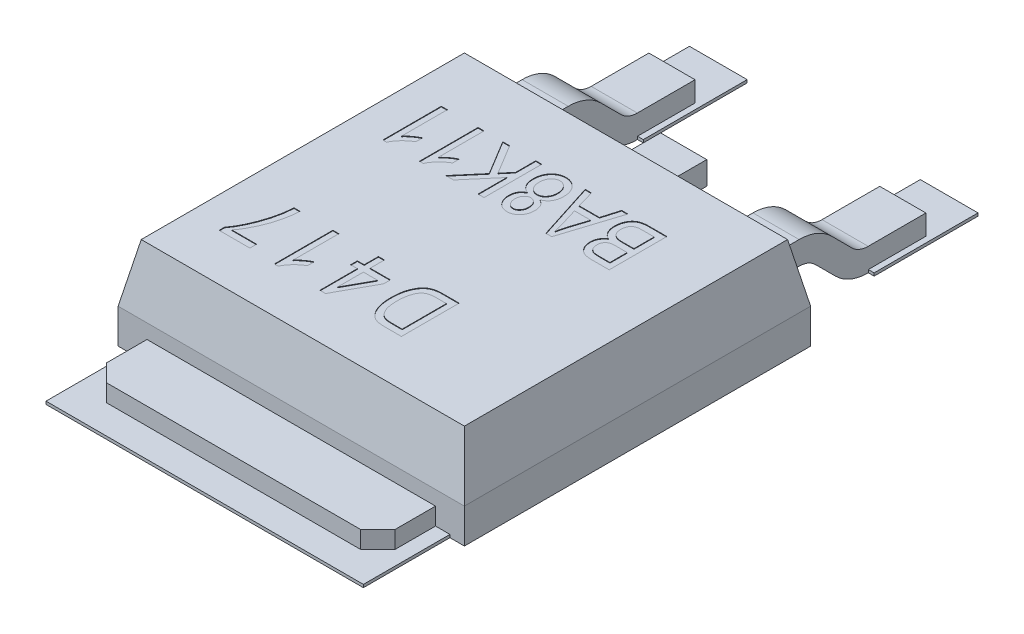
from build123d import *
from OCP.BRepFilletAPI import BRepFilletAPI_MakeChamfer

# Parameters (mm, degrees)
SKETCH1_W           = 6
SKETCH1_H           = 6
BOSS_EXTRUDE1_DEPTH = 1.6
CHAMFER1_SIZE       = 1
CHAMFER1_SIZE2      = 0.2
BOSS_EXTRU_1_DEPTH  = 0.35
SKETCH4_W           = 5.5
SKETCH4_H           = 2
SKETCH4_W_2         = 1
SKETCH4_H_2         = 1.8
BOSS_EXTRUDE2_DEPTH = 0.05
CUT_EXTRUDE1_DEPTH  = 0.01
CUT_EXTRUDE2_DEPTH  = 0.01
EXTRU_MINCE1_DEPTH  = 0.4
ESQUISSE3_W         = 1
ESQUISSE3_H         = 0.4
EXTRU_MINCE2_DEPTH  = 0.4


with BuildPart() as part:
    # Sketch1 → Boss-Extrude1 (new body)
    with BuildSketch(Plane(origin=(0, 0, 0), x_dir=(1, 0, 0), z_dir=(0, 1, 0))):
        Rectangle(SKETCH1_W, SKETCH1_H)
    extrude(amount=BOSS_EXTRUDE1_DEPTH)

    # Chamfer1: one chamfer whose edges measure the first distance from different faces: ONE call of the kernel's chamfer builder (chamfer() names one face for all edges)
    chamfer1_edges_1 = [part.edges().sort_by_distance(p)[0] for p in [
        (3, 1.6, 0),
    ]]
    chamfer1_side_1 = [part.faces().sort_by_distance(p)[0] for p in [
        (3, 0.8, 0),
    ]]
    chamfer1_edges_2 = [part.edges().sort_by_distance(p)[0] for p in [
        (0, 1.6, -3),
    ]]
    chamfer1_side_2 = [part.faces().sort_by_distance(p)[0] for p in [
        (0, 0.8, -3),
    ]]
    chamfer1_edges_3 = [part.edges().sort_by_distance(p)[0] for p in [
        (-3, 1.6, 0),
    ]]
    chamfer1_side_3 = [part.faces().sort_by_distance(p)[0] for p in [
        (-3, 0.8, 0),
    ]]
    chamfer1_edges_4 = [part.edges().sort_by_distance(p)[0] for p in [
        (0, 1.6, 3),
    ]]
    chamfer1_side_4 = [part.faces().sort_by_distance(p)[0] for p in [
        (0, 0.8, 3),
    ]]
    chamfer1 = BRepFilletAPI_MakeChamfer(part.part.solid().wrapped)
    for e in chamfer1_edges_1:
        chamfer1.Add(CHAMFER1_SIZE, CHAMFER1_SIZE2, e.wrapped, chamfer1_side_1[0].wrapped)  # the first distance lies on this face
    for e in chamfer1_edges_2:
        chamfer1.Add(CHAMFER1_SIZE, CHAMFER1_SIZE2, e.wrapped, chamfer1_side_2[0].wrapped)  # the first distance lies on this face
    for e in chamfer1_edges_3:
        chamfer1.Add(CHAMFER1_SIZE, CHAMFER1_SIZE2, e.wrapped, chamfer1_side_3[0].wrapped)  # the first distance lies on this face
    for e in chamfer1_edges_4:
        chamfer1.Add(CHAMFER1_SIZE, CHAMFER1_SIZE2, e.wrapped, chamfer1_side_4[0].wrapped)  # the first distance lies on this face
    add(Compound.cast(chamfer1.Shape()), mode=Mode.REPLACE)

    # Esquisse1 → Boss.-Extru.1 (add)
    with BuildSketch(Plane.XZ):
        Polygon((-2.5, 3), (-2.5, 3.7), (-2.2, 4), (2.2, 4), (2.5, 3.7), (2.5, 3), align=None)
    extrude(amount=-BOSS_EXTRU_1_DEPTH)

    # Sketch4 → Boss-Extrude2 (add)
    with BuildSketch(Plane(origin=(0, 0, 0), x_dir=(1, 0, 0), z_dir=(0, 1, 0))):
        with Locations((0, -3.5)):
            Rectangle(SKETCH4_W, SKETCH4_H)
        with Locations((-2, 5.5)):
            Rectangle(SKETCH4_W_2, SKETCH4_H_2)
        with Locations((2, 5.5)):
            Rectangle(SKETCH4_W_2, SKETCH4_H_2)
    extrude(amount=BOSS_EXTRUDE2_DEPTH)


with BuildPart() as boss_extrude2_piece_1:
    # of the separate pieces the step leaves, piece 1, a body of its own (boss_extrude2_pieces)
    add(part.part.solids().sort_by_distance((-3, 0.6, -3))[0])

    # Sketch5 → Cut-Extrude1 (cut)
    with BuildSketch(Plane(origin=(0, 1.6, 0), x_dir=(1, 0, 0), z_dir=(0, 1, 0))):
        with BuildLine():
            Line((0.909090909, -1), (0.909090909, -2))
            Line((0.909090909, -2), (0.627232143, -2))
            add(Edge.make_bspline(
                [(0.627232143, -2), (0.618775412, -2.00000451), (0.60239621, -2.000013245), (0.578587199, -1.998844327), (0.556316091, -1.997536776), (0.535597034, -1.995541178), (0.516529087, -1.992843094), (0.498939821, -1.989939618), (0.482975595, -1.986074805), (0.472930515, -1.983000063), (0.468141234, -1.981534091)],
                knots=[0, 0, 0, 0, 1.262174937, 2.444611131, 3.557536157, 4.59237566, 5.550534478, 6.431992477, 7.252407118, 8, 8, 8, 8], degree=3))
            add(Edge.make_bspline(
                [(0.468141234, -1.981534091), (0.456481577, -1.977077241), (0.433154022, -1.96816039), (0.400785725, -1.948392912), (0.370967262, -1.923721279), (0.343505704, -1.894318821), (0.318800848, -1.860334626), (0.297135486, -1.822023974), (0.278003099, -1.779895789), (0.26197546, -1.733511256), (0.249196519, -1.682818235), (0.240254127, -1.627627934), (0.23471847, -1.568024588), (0.234090817, -1.526798491), (0.233766234, -1.505478896)],
                knots=[0, 0, 0, 0, 0.793570228, 1.587701398, 2.401757725, 3.251990999, 4.14284781, 5.070886882, 6.05016333, 7.085482446, 8.191842001, 9.375152492, 10.642590783, 12, 12, 12, 12], degree=3))
            add(Edge.make_bspline(
                [(0.233766234, -1.505478896), (0.233936524, -1.491609851), (0.234271511, -1.464327235), (0.236476558, -1.424242192), (0.240312254, -1.385711603), (0.245787602, -1.348883148), (0.252663112, -1.313580679), (0.261094381, -1.279946144), (0.271346301, -1.247947411), (0.282845805, -1.217593758), (0.295542964, -1.189045638), (0.309363547, -1.1626511), (0.323967898, -1.138314333), (0.339601771, -1.116289027), (0.355796369, -1.096150943), (0.373181339, -1.078498187), (0.391220094, -1.062685269), (0.410533963, -1.049188647), (0.431048809, -1.03758525), (0.452795028, -1.027390955), (0.476077229, -1.018828152), (0.500887314, -1.012045721), (0.527097788, -1.006515321), (0.554830261, -1.002702364), (0.584041134, -1.000496637), (0.604027564, -1.000168005), (0.61424513, -1)],
                knots=[0, 0, 0, 0, 1.386035777, 2.726552658, 4.010606465, 5.254366226, 6.446193604, 7.603690686, 8.717510246, 9.802231389, 10.846187194, 11.837930809, 12.77813523, 13.6802668, 14.53543628, 15.357642445, 16.153183888, 16.929597682, 17.707687034, 18.506066684, 19.327327497, 20.183458262, 21.074376462, 22.002646263, 22.978902547, 24, 24, 24, 24], degree=3))
            Line((0.61424513, -1), (0.909090909, -1))
        make_face()
        with BuildLine():
            Line((0.805194805, -1.116883117), (0.626826299, -1.116883117))
            add(Edge.make_bspline(
                [(0.626826299, -1.116883117), (0.618097699, -1.117005877), (0.601166151, -1.117244005), (0.576588709, -1.118906443), (0.553598984, -1.12141978), (0.53226459, -1.125313856), (0.512582747, -1.130105742), (0.494498004, -1.135992591), (0.478070061, -1.143079418), (0.463030763, -1.15126581), (0.44932786, -1.16069055), (0.436604076, -1.171408607), (0.424660749, -1.18336333), (0.413499295, -1.196621802), (0.403028313, -1.211046266), (0.393783985, -1.227072232), (0.384996644, -1.244233052), (0.3799878, -1.256386977), (0.377435065, -1.262581169)],
                knots=[0, 0, 0, 0, 1.342522454, 2.604195873, 3.787640691, 4.897837639, 5.937490788, 6.901507558, 7.81956877, 8.685632238, 9.531204737, 10.37312076, 11.241244131, 12.127141563, 13.036673505, 13.978826353, 14.969918024, 16, 16, 16, 16], degree=3))
            add(Edge.make_bspline(
                [(0.377435065, -1.262581169), (0.374235057, -1.271275904), (0.367767595, -1.28884863), (0.359550223, -1.316254887), (0.353107863, -1.344993201), (0.347201712, -1.374924433), (0.343189551, -1.406125809), (0.339760984, -1.438585087), (0.338026764, -1.472315755), (0.33778495, -1.495263627), (0.337662338, -1.506899351)],
                knots=[0, 0, 0, 0, 0.893151802, 1.805128209, 2.755850574, 3.731738016, 4.745334486, 5.787480394, 6.878141491, 8, 8, 8, 8], degree=3))
            add(Edge.make_bspline(
                [(0.337662338, -1.506899351), (0.337751243, -1.51928112), (0.337924325, -1.543386024), (0.340069251, -1.578512545), (0.343150431, -1.611578414), (0.347889282, -1.64258153), (0.353717899, -1.671581071), (0.3606963, -1.698616756), (0.369273581, -1.723571691), (0.379178025, -1.746475475), (0.390248858, -1.767369446), (0.401717861, -1.786658084), (0.414363885, -1.803853952), (0.42754419, -1.819364746), (0.441467336, -1.833160595), (0.456190791, -1.845094558), (0.471786112, -1.855222075), (0.48275985, -1.860566298), (0.488230519, -1.863230519)],
                knots=[0, 0, 0, 0, 1.456515219, 2.835552549, 4.138945756, 5.362336007, 6.523499621, 7.617953034, 8.644754834, 9.624918001, 10.550413316, 11.425253886, 12.262512803, 13.058355621, 13.818045382, 14.564998839, 15.284617782, 16, 16, 16, 16], degree=3))
            add(Edge.make_bspline(
                [(0.488230519, -1.863230519), (0.492196312, -1.864856582), (0.500541033, -1.868278102), (0.514225775, -1.872201089), (0.529448542, -1.875715827), (0.546367242, -1.878175199), (0.564826162, -1.880463596), (0.584997618, -1.882110126), (0.606800225, -1.882783141), (0.62188835, -1.883003351), (0.629667208, -1.883116883)],
                knots=[0, 0, 0, 0, 0.715292366, 1.505100173, 2.373764653, 3.322734101, 4.358121183, 5.480036167, 6.700803291, 8, 8, 8, 8], degree=3))
            Line((0.629667208, -1.883116883), (0.805194805, -1.883116883))
            Line((0.805194805, -1.883116883), (0.805194805, -1.116883117))
        make_face(mode=Mode.SUBTRACT)
        Polygon((-0.386363636, -1), (-0.386363636, -1.246753247), (-0.035714286, -1.246753247), (-0.035714286, -1.363636364), (-0.392248377, -2.012987013), (-0.49025974, -2.012987013), (-0.49025974, -1.363636364), (-0.607142857, -1.363636364), (-0.607142857, -1.246753247), (-0.49025974, -1.246753247), (-0.49025974, -1), align=None)
        Polygon((-0.386363636, -1.363636364), (-0.386363636, -1.815543831), (-0.138189935, -1.363636364), align=None, mode=Mode.SUBTRACT)
        with BuildLine():
            Line((-1.279220779, -1), (-1.175324675, -1))
            Line((-1.175324675, -1), (-1.175324675, -1.792207792))
            add(Edge.make_bspline(
                [(-1.175324675, -1.792207792), (-1.168941155, -1.784866534), (-1.155711315, -1.769651785), (-1.132836194, -1.747977094), (-1.107121801, -1.725961756), (-1.079062769, -1.70412581), (-1.050104506, -1.683443988), (-1.021591711, -1.665041869), (-0.994416181, -1.649140319), (-0.976251606, -1.640507471), (-0.967532468, -1.636363636)],
                knots=[0, 0, 0, 0, 0.892597597, 1.849907605, 2.889096657, 3.999508354, 5.112538398, 6.154543284, 7.114166246, 8, 8, 8, 8], degree=3))
            Line((-0.967532468, -1.636363636), (-0.967532468, -1.753246753))
            add(Edge.make_bspline(
                [(-0.967532468, -1.753246753), (-0.981542686, -1.761684938), (-1.009443158, -1.778489054), (-1.048633979, -1.807549853), (-1.085439436, -1.839249281), (-1.119295093, -1.873145958), (-1.149602414, -1.908063441), (-1.175168336, -1.943201804), (-1.196425732, -1.977703086), (-1.206826798, -2.00149514), (-1.211850649, -2.012987013)],
                knots=[0, 0, 0, 0, 1.082266703, 2.155266233, 3.225308806, 4.295585612, 5.324342242, 6.282751181, 7.17054637, 8, 8, 8, 8], degree=3))
            Line((-1.211850649, -2.012987013), (-1.279220779, -2.012987013))
            Line((-1.279220779, -2.012987013), (-1.279220779, -1))
        make_face()
        with BuildLine():
            Line((-1.730519481, -1.87012987), (-1.730519481, -1.987012987))
            Line((-1.730519481, -1.987012987), (-2.262987013, -1.987012987))
            Line((-2.262987013, -1.987012987), (-2.262987013, -1.891436688))
            add(Edge.make_bspline(
                [(-2.262987013, -1.891436688), (-2.253107587, -1.878210031), (-2.232998474, -1.851287786), (-2.204877796, -1.808222134), (-2.177523491, -1.762359182), (-2.150938602, -1.713647147), (-2.125334602, -1.662005922), (-2.100887544, -1.607370332), (-2.077158554, -1.54991053), (-2.054393858, -1.490126812), (-2.033180943, -1.428934513), (-2.014319685, -1.367266072), (-1.997878532, -1.305656703), (-1.983655189, -1.244287077), (-1.971819574, -1.183038154), (-1.962512462, -1.121977409), (-1.955512302, -1.060986446), (-1.952701618, -1.020305417), (-1.951298701, -1)],
                knots=[0, 0, 0, 0, 0.828261285, 1.685887316, 2.579428271, 3.507501538, 4.469891598, 5.471065063, 6.510494938, 7.589089173, 8.680758398, 9.759817177, 10.82439165, 11.879940066, 12.920405774, 13.953938893, 14.978734705, 16, 16, 16, 16], degree=3))
            Line((-1.951298701, -1), (-1.847402597, -1))
            add(Edge.make_bspline(
                [(-1.847402597, -1), (-1.847750245, -1.010689632), (-1.848459293, -1.032491751), (-1.850659887, -1.065872605), (-1.854401087, -1.100508476), (-1.859272188, -1.1365078), (-1.865445265, -1.173762929), (-1.872455889, -1.212439498), (-1.881062772, -1.252330181), (-1.894016685, -1.307156239), (-1.912517131, -1.375703545), (-1.93909059, -1.456512779), (-1.969148541, -1.535436954), (-2.003256405, -1.611554138), (-2.039186803, -1.684140455), (-2.07765803, -1.751351867), (-2.116488053, -1.813642595), (-2.145154103, -1.85165101), (-2.159090909, -1.87012987)],
                knots=[0, 0, 0, 0, 0.547564817, 1.116789984, 1.712252562, 2.330831182, 2.976456312, 3.645516887, 4.343080939, 5.06547646, 6.529779861, 7.976466419, 9.419056042, 10.851576025, 12.245448489, 13.563727135, 14.815537433, 16, 16, 16, 16], degree=3))
            Line((-2.159090909, -1.87012987), (-1.730519481, -1.87012987))
        make_face()
    extrude(amount=-CUT_EXTRUDE1_DEPTH, mode=Mode.SUBTRACT)

    # Sketch6 → Cut-Extrude2 (cut)
    with BuildSketch(Plane(origin=(0, 1.6, 0), x_dir=(1, 0, 0), z_dir=(0, 1, 0))):
        with BuildLine():
            Line((1.709090909, 1.8), (1.709090909, 0.8))
            Line((1.709090909, 0.8), (1.399025974, 0.8))
            add(Edge.make_bspline(
                [(1.399025974, 0.8), (1.391379972, 0.800054737), (1.376479609, 0.800161407), (1.35474923, 0.801658249), (1.334234107, 0.803862586), (1.314898025, 0.806818804), (1.296886513, 0.810896293), (1.280041716, 0.815744905), (1.264459217, 0.821633249), (1.245258892, 0.830494742), (1.223120185, 0.844304649), (1.199134695, 0.864843401), (1.177779684, 0.889492317), (1.159040297, 0.917539877), (1.143625845, 0.948366452), (1.132659113, 0.981294216), (1.125938203, 1.015839329), (1.125101346, 1.039417471), (1.124675325, 1.051420455)],
                knots=[0, 0, 0, 0, 0.870762362, 1.696922705, 2.479694412, 3.220704395, 3.923519284, 4.58180529, 5.215744372, 5.818975064, 6.988484834, 8.174326093, 9.402850172, 10.691394685, 12.007628492, 13.315991423, 14.633645104, 16, 16, 16, 16], degree=3))
            add(Edge.make_bspline(
                [(1.124675325, 1.051420455), (1.125012224, 1.062469532), (1.125673818, 1.084167395), (1.131294903, 1.115801747), (1.140432431, 1.145758504), (1.153339228, 1.173770644), (1.169199712, 1.19991493), (1.18879568, 1.223013033), (1.210790177, 1.244063188), (1.227706367, 1.255327982), (1.236282468, 1.261038961)],
                knots=[0, 0, 0, 0, 1.067163608, 2.095665496, 3.094381775, 4.086055985, 5.069334826, 6.039400011, 7.006023047, 8, 8, 8, 8], degree=3))
            add(Edge.make_bspline(
                [(1.236282468, 1.261038961), (1.22600209, 1.265827966), (1.205531205, 1.275364113), (1.178368523, 1.29598836), (1.15440453, 1.320887189), (1.134393073, 1.35051673), (1.118310935, 1.384223727), (1.106796572, 1.421742795), (1.099812443, 1.462889136), (1.099080571, 1.49152962), (1.098701299, 1.506371753)],
                knots=[0, 0, 0, 0, 0.907806387, 1.807676924, 2.717428127, 3.670336734, 4.663211712, 5.703492116, 6.809898713, 8, 8, 8, 8], degree=3))
            add(Edge.make_bspline(
                [(1.098701299, 1.506371753), (1.099078652, 1.521283338), (1.099811987, 1.550262045), (1.106983705, 1.592270609), (1.118188705, 1.631554649), (1.134224832, 1.66761609), (1.154018015, 1.699906758), (1.177096466, 1.727895878), (1.203311481, 1.751153558), (1.227873534, 1.766535285), (1.249305953, 1.77614511), (1.266729866, 1.782748339), (1.285740342, 1.787857683), (1.306033096, 1.792382826), (1.327857783, 1.795816529), (1.351100626, 1.798103731), (1.375730043, 1.799903222), (1.39259649, 1.799967164), (1.401258117, 1.8)],
                knots=[0, 0, 0, 0, 1.483101461, 2.882213003, 4.228804869, 5.540004403, 6.797554673, 7.988070595, 9.137672878, 10.271731903, 10.856259808, 11.474079914, 12.124255131, 12.813652303, 13.543114926, 14.321609254, 15.138076009, 16, 16, 16, 16], degree=3))
            Line((1.401258117, 1.8), (1.709090909, 1.8))
        make_face()
        with BuildLine():
            Line((1.605194805, 1.215584416), (1.421753247, 1.215584416))
            add(Edge.make_bspline(
                [(1.421753247, 1.215584416), (1.410653992, 1.215504138), (1.390129319, 1.215355689), (1.361987025, 1.213421056), (1.338789187, 1.211138), (1.325406025, 1.207609396), (1.319480519, 1.206047078)],
                knots=[0, 0, 0, 0, 1.292436319, 2.38996507, 3.287143691, 4, 4, 4, 4], degree=3))
            add(Edge.make_bspline(
                [(1.319480519, 1.206047078), (1.312542258, 1.203575452), (1.298988065, 1.198747023), (1.28083443, 1.187697451), (1.26482608, 1.17461566), (1.251549462, 1.15881063), (1.240829716, 1.140289002), (1.233795941, 1.118658579), (1.229198572, 1.094228534), (1.228787545, 1.076944839), (1.228571429, 1.067857143)],
                knots=[0, 0, 0, 0, 0.985455176, 1.925129435, 2.833409245, 3.74751417, 4.678036112, 5.68496882, 6.782766118, 8, 8, 8, 8], degree=3))
            add(Edge.make_bspline(
                [(1.228571429, 1.067857143), (1.228830522, 1.059315913), (1.229327246, 1.042940959), (1.233478133, 1.019477123), (1.240087212, 0.998185735), (1.2494136, 0.979214978), (1.261076363, 0.962840987), (1.274599342, 0.949004357), (1.2899696, 0.93796315), (1.304319142, 0.930893334), (1.3173713, 0.927006428), (1.328912934, 0.924086669), (1.342370093, 0.921981149), (1.357544365, 0.920246836), (1.37444135, 0.918498491), (1.39313363, 0.917619635), (1.413564079, 0.916981608), (1.427772613, 0.916916766), (1.435146104, 0.916883117)],
                knots=[0, 0, 0, 0, 1.374823033, 2.635763691, 3.824462367, 4.954815379, 6.024974192, 7.049578075, 8.056420344, 9.060192966, 9.608067978, 10.247510764, 10.976465608, 11.799414685, 12.707848295, 13.711620916, 14.812450139, 16, 16, 16, 16], degree=3))
            Line((1.435146104, 0.916883117), (1.605194805, 0.916883117))
            Line((1.605194805, 0.916883117), (1.605194805, 1.215584416))
        make_face(mode=Mode.SUBTRACT)
        with BuildLine():
            Line((1.605194805, 1.683116883), (1.399025974, 1.683116883))
            add(Edge.make_bspline(
                [(1.399025974, 1.683116883), (1.388401593, 1.682961147), (1.368614295, 1.682671096), (1.341133252, 1.680603566), (1.31801264, 1.676848839), (1.304495734, 1.672503054), (1.298376623, 1.670535714)],
                knots=[0, 0, 0, 0, 1.250964288, 2.329849019, 3.243921745, 4, 4, 4, 4], degree=3))
            add(Edge.make_bspline(
                [(1.298376623, 1.670535714), (1.290859518, 1.667282728), (1.276193291, 1.660935997), (1.256844935, 1.647017306), (1.239879566, 1.630785821), (1.226253555, 1.611185955), (1.215635897, 1.588885306), (1.207946016, 1.564023054), (1.203532087, 1.536424303), (1.202917918, 1.517210521), (1.202597403, 1.507183442)],
                knots=[0, 0, 0, 0, 0.967993686, 1.888601442, 2.806833432, 3.738608885, 4.699374536, 5.72357697, 6.812005123, 8, 8, 8, 8], degree=3))
            add(Edge.make_bspline(
                [(1.202597403, 1.507183442), (1.202829078, 1.497896151), (1.203276768, 1.479949339), (1.207868279, 1.454178508), (1.215104403, 1.430588423), (1.225295109, 1.409313134), (1.238065552, 1.390582178), (1.253137342, 1.374614588), (1.26987555, 1.36091141), (1.285804804, 1.352046381), (1.299981138, 1.346382429), (1.312025001, 1.342524545), (1.325641811, 1.339588785), (1.340523686, 1.336941513), (1.356848319, 1.334921668), (1.374525439, 1.333613795), (1.393600033, 1.332453516), (1.406802604, 1.332462752), (1.413636364, 1.332467532)],
                knots=[0, 0, 0, 0, 1.410573788, 2.725800822, 3.964903627, 5.151480749, 6.298041429, 7.396564004, 8.478942006, 9.57457322, 10.151232655, 10.798392405, 11.494360327, 12.266936039, 13.095957466, 13.993447348, 14.961391824, 16, 16, 16, 16], degree=3))
            Line((1.413636364, 1.332467532), (1.605194805, 1.332467532))
            Line((1.605194805, 1.332467532), (1.605194805, 1.683116883))
        make_face(mode=Mode.SUBTRACT)
        Polygon((1.033766234, 1.8), (0.714366883, 0.8), (0.613108766, 0.8), (0.293506494, 1.8), (0.401461039, 1.8), (0.488920455, 1.501298701), (0.838352273, 1.501298701), (0.925608766, 1.8), align=None)
        with BuildLine():
            Line((0.804261364, 1.384415584), (0.523214286, 1.384415584))
            Line((0.523214286, 1.384415584), (0.606818182, 1.109659091))
            add(Edge.make_bspline(
                [(0.606818182, 1.109659091), (0.609943302, 1.099381806), (0.616044644, 1.079316904), (0.624726603, 1.049947394), (0.632908616, 1.022030462), (0.640419515, 0.99560057), (0.647062127, 0.970607104), (0.653235429, 0.947157072), (0.658669278, 0.925160817), (0.662024566, 0.910933488), (0.663636364, 0.904099026)],
                knots=[0, 0, 0, 0, 1.208585302, 2.359586633, 3.44573617, 4.481694954, 5.45087266, 6.355352717, 7.20995158, 8, 8, 8, 8], degree=3))
            add(Edge.make_bspline(
                [(0.663636364, 0.904099026), (0.666559949, 0.920019234), (0.672403236, 0.951838502), (0.683356248, 0.999239199), (0.695541806, 1.04655436), (0.705241061, 1.077769848), (0.710105519, 1.093425325)],
                knots=[0, 0, 0, 0, 0.995500629, 1.989678841, 2.991765375, 4, 4, 4, 4], degree=3))
            Line((0.710105519, 1.093425325), (0.804261364, 1.384415584))
        make_face(mode=Mode.SUBTRACT)
        with BuildLine():
            add(Edge.make_bspline(
                [(0.055073052, 1.251298701), (0.06462921, 1.246491383), (0.083273438, 1.237112222), (0.108139677, 1.218830253), (0.12914444, 1.19737835), (0.146566292, 1.172965679), (0.160360127, 1.145492643), (0.169686672, 1.114812189), (0.175815864, 1.081223702), (0.176347218, 1.057740526), (0.176623377, 1.045535714)],
                knots=[0, 0, 0, 0, 1.008509637, 1.967619574, 2.89776806, 3.831547644, 4.788167516, 5.785783694, 6.849214744, 8, 8, 8, 8], degree=3))
            add(Edge.make_bspline(
                [(0.176623377, 1.045535714), (0.176437496, 1.036192949), (0.176074127, 1.01792923), (0.172968249, 0.99118185), (0.167878134, 0.96582057), (0.161102457, 0.941683442), (0.151850327, 0.919021466), (0.140609062, 0.89768413), (0.127678992, 0.87738583), (0.112439714, 0.85891933), (0.095911173, 0.842089289), (0.078177815, 0.827378272), (0.059412853, 0.814910076), (0.039612401, 0.804691252), (0.018781155, 0.796754339), (-0.003104633, 0.790979993), (-0.02607062, 0.787808644), (-0.041711805, 0.78728051), (-0.04963474, 0.787012987)],
                knots=[0, 0, 0, 0, 1.165741532, 2.278851694, 3.354982323, 4.391648623, 5.402771003, 6.403407807, 7.398581389, 8.400606014, 9.38555839, 10.33889109, 11.270751962, 12.191998689, 13.113864065, 14.047558559, 15.011004111, 16, 16, 16, 16], degree=3))
            add(Edge.make_bspline(
                [(-0.04963474, 0.787012987), (-0.057628477, 0.787257493), (-0.073420297, 0.787740521), (-0.096550565, 0.79124631), (-0.118652568, 0.796951233), (-0.13974026, 0.804861825), (-0.159695435, 0.815329769), (-0.178664421, 0.827989647), (-0.196651133, 0.84291662), (-0.213354584, 0.860076787), (-0.228476677, 0.879063823), (-0.241802257, 0.899480577), (-0.252942164, 0.921272034), (-0.262145499, 0.94436096), (-0.269241336, 0.968830901), (-0.274246983, 0.994639674), (-0.27736951, 1.021717189), (-0.277735543, 1.040183505), (-0.277922078, 1.049594156)],
                knots=[0, 0, 0, 0, 0.984942696, 1.945778183, 2.875853341, 3.793971666, 4.714923987, 5.646678758, 6.59981698, 7.590177482, 8.592638326, 9.586885563, 10.589796896, 11.603734109, 12.645759419, 13.72477449, 14.840518438, 16, 16, 16, 16], degree=3))
            add(Edge.make_bspline(
                [(-0.277922078, 1.049594156), (-0.277623933, 1.061322759), (-0.277049626, 1.083915245), (-0.271179536, 1.116373217), (-0.26194147, 1.146057318), (-0.248872785, 1.173038658), (-0.231761321, 1.197212749), (-0.21060629, 1.218269845), (-0.185967661, 1.23704401), (-0.16723645, 1.246452851), (-0.157589286, 1.251298701)],
                knots=[0, 0, 0, 0, 1.126050265, 2.169079615, 3.157896424, 4.105607084, 5.038058818, 5.989507118, 6.964532763, 8, 8, 8, 8], degree=3))
            add(Edge.make_bspline(
                [(-0.157589286, 1.251298701), (-0.163863221, 1.253825326), (-0.176231325, 1.258806179), (-0.193694264, 1.268119642), (-0.210261126, 1.278221263), (-0.225636349, 1.289600489), (-0.239975187, 1.301999742), (-0.253009459, 1.315720356), (-0.264955392, 1.330559912), (-0.275937671, 1.34638906), (-0.285802125, 1.36328233), (-0.29396598, 1.381383717), (-0.30120549, 1.400307772), (-0.306800686, 1.420303094), (-0.311283836, 1.441245123), (-0.314456736, 1.463142164), (-0.316616901, 1.486036367), (-0.316792954, 1.501631656), (-0.316883117, 1.509618506)],
                knots=[0, 0, 0, 0, 0.998651006, 1.968687807, 2.92001032, 3.863478588, 4.791415673, 5.717413269, 6.655466888, 7.60358177, 8.561808628, 9.541119464, 10.534204117, 11.552808826, 12.605410886, 13.696544253, 14.820325946, 16, 16, 16, 16], degree=3))
            add(Edge.make_bspline(
                [(-0.316883117, 1.509618506), (-0.316663065, 1.520520039), (-0.316231243, 1.54191283), (-0.312439175, 1.573184234), (-0.306647737, 1.603015311), (-0.29832938, 1.631293039), (-0.287576764, 1.658036037), (-0.274229477, 1.683094202), (-0.258839409, 1.706796325), (-0.240962695, 1.72858043), (-0.221513755, 1.748346409), (-0.200588919, 1.765556267), (-0.17861842, 1.780268663), (-0.155390732, 1.792391575), (-0.130846761, 1.801406032), (-0.105347592, 1.80828286), (-0.078630747, 1.812079167), (-0.060468204, 1.81268155), (-0.051258117, 1.812987013)],
                knots=[0, 0, 0, 0, 1.159839339, 2.276028545, 3.347612162, 4.390892238, 5.408217009, 6.409728542, 7.408078517, 8.410986246, 9.403635706, 10.354881406, 11.289307082, 12.213387266, 13.136008139, 14.066710435, 15.019643562, 16, 16, 16, 16], degree=3))
            add(Edge.make_bspline(
                [(-0.051258117, 1.812987013), (-0.041912383, 1.812684937), (-0.023546717, 1.812091316), (0.003434463, 1.808274575), (0.029089632, 1.801452219), (0.053723163, 1.792332286), (0.077089426, 1.780341376), (0.099097415, 1.765482672), (0.1202067, 1.748421154), (0.139666409, 1.728576225), (0.157560972, 1.706701961), (0.173199517, 1.683001557), (0.186263619, 1.657510294), (0.197063592, 1.630485334), (0.205289841, 1.601701102), (0.211497041, 1.571330766), (0.214838686, 1.539252774), (0.21533269, 1.517336533), (0.215584416, 1.506168831)],
                knots=[0, 0, 0, 0, 0.98489838, 1.935462181, 2.863853923, 3.777350714, 4.698628449, 5.623813301, 6.571164825, 7.553997668, 8.546987334, 9.545334758, 10.539960322, 11.560453443, 12.607097128, 13.690449471, 14.823138845, 16, 16, 16, 16], degree=3))
            add(Edge.make_bspline(
                [(0.215584416, 1.506168831), (0.215483834, 1.497980693), (0.2152865, 1.481916075), (0.21325521, 1.458316252), (0.209689433, 1.435866449), (0.205477, 1.414399622), (0.19914804, 1.394217724), (0.192025374, 1.374918019), (0.183215971, 1.356843904), (0.17328675, 1.339912169), (0.162066167, 1.324294868), (0.149938938, 1.309823435), (0.136633024, 1.296775908), (0.122373352, 1.284976186), (0.107119449, 1.27429625), (0.090667318, 1.265269324), (0.073296389, 1.257438759), (0.061199065, 1.253362762), (0.055073052, 1.251298701)],
                knots=[0, 0, 0, 0, 1.21069923, 2.375316522, 3.498562823, 4.571653073, 5.606389256, 6.622587272, 7.611287731, 8.575394897, 9.521906623, 10.45172785, 11.364169739, 12.273481081, 13.186361486, 14.113218831, 15.04454532, 16, 16, 16, 16], degree=3))
        make_face()
        with BuildLine():
            add(Edge.make_bspline(
                [(0.072727273, 1.042694805), (0.072334718, 1.05429437), (0.071583593, 1.076489257), (0.064929041, 1.107992264), (0.053449067, 1.135714129), (0.037780811, 1.159333908), (0.019006055, 1.17864292), (-0.002496631, 1.192537149), (-0.026199418, 1.201248377), (-0.04279643, 1.202141871), (-0.051258117, 1.202597403)],
                knots=[0, 0, 0, 0, 1.231842103, 2.357036451, 3.401085995, 4.401996228, 5.352590176, 6.24195284, 7.103691345, 8, 8, 8, 8], degree=3))
            add(Edge.make_bspline(
                [(-0.051258117, 1.202597403), (-0.05951953, 1.202139944), (-0.075790566, 1.20123897), (-0.099014689, 1.192463158), (-0.120261404, 1.178815235), (-0.13902922, 1.160008749), (-0.154588469, 1.1370931), (-0.166145949, 1.110655796), (-0.172858563, 1.080972077), (-0.173627121, 1.060181013), (-0.174025974, 1.049391234)],
                knots=[0, 0, 0, 0, 0.904469837, 1.78137328, 2.690563844, 3.66281761, 4.679099383, 5.717479744, 6.815457862, 8, 8, 8, 8], degree=3))
            add(Edge.make_bspline(
                [(-0.174025974, 1.049391234), (-0.173647026, 1.038259859), (-0.172915732, 1.01677852), (-0.16591102, 0.986120949), (-0.154266296, 0.958653161), (-0.1382652, 0.934956367), (-0.11912781, 0.915587535), (-0.097707501, 0.901483499), (-0.0744582, 0.892499958), (-0.058235954, 0.891443039), (-0.050040584, 0.890909091)],
                knots=[0, 0, 0, 0, 1.194512566, 2.305171441, 3.356745246, 4.382694336, 5.359056102, 6.262072859, 7.122010972, 8, 8, 8, 8], degree=3))
            add(Edge.make_bspline(
                [(-0.050040584, 0.890909091), (-0.041851708, 0.8913798), (-0.025658138, 0.892310631), (-0.002461566, 0.900962101), (0.018588946, 0.914991475), (0.03731905, 0.933958771), (0.053037881, 0.956875073), (0.064473297, 0.983104616), (0.071635735, 1.012013395), (0.072355133, 1.032234538), (0.072727273, 1.042694805)],
                knots=[0, 0, 0, 0, 0.904441632, 1.788540613, 2.702983884, 3.688499748, 4.723534326, 5.763574655, 6.843111586, 8, 8, 8, 8], degree=3))
        make_face(mode=Mode.SUBTRACT)
        with BuildLine():
            add(Edge.make_bspline(
                [(0.111688312, 1.505762987), (0.111524855, 1.5132094), (0.111204621, 1.527797932), (0.108926213, 1.549093346), (0.105366907, 1.569280394), (0.100081212, 1.588318755), (0.093066519, 1.606154632), (0.085061755, 1.623134625), (0.07527625, 1.638883343), (0.063808316, 1.653089993), (0.051838681, 1.666365736), (0.03880998, 1.677682585), (0.025289244, 1.687333129), (0.011221728, 1.695415786), (-0.003647745, 1.701391205), (-0.018973462, 1.705970956), (-0.034927846, 1.708679191), (-0.045769056, 1.708952519), (-0.051258117, 1.709090909)],
                knots=[0, 0, 0, 0, 1.230277288, 2.410279697, 3.534938767, 4.614252728, 5.668684243, 6.698481287, 7.712631841, 8.723327437, 9.712029744, 10.662530755, 11.568139775, 12.45401456, 13.336144453, 14.209736028, 15.093563688, 16, 16, 16, 16], degree=3))
            add(Edge.make_bspline(
                [(-0.051258117, 1.709090909), (-0.056817292, 1.708963543), (-0.067731038, 1.708713499), (-0.083766298, 1.705875442), (-0.099170076, 1.701713084), (-0.113916557, 1.695723865), (-0.128053214, 1.68818963), (-0.141437667, 1.678815971), (-0.154133938, 1.667646261), (-0.166222103, 1.65505418), (-0.177095103, 1.640856214), (-0.186750386, 1.625537858), (-0.194806787, 1.609044289), (-0.201619848, 1.591501373), (-0.206610615, 1.572699829), (-0.210242269, 1.552751293), (-0.212499031, 1.53165282), (-0.212822088, 1.517199877), (-0.212987013, 1.509821429)],
                knots=[0, 0, 0, 0, 0.929227775, 1.824255418, 2.716702898, 3.59526155, 4.481442626, 5.392008749, 6.322614179, 7.307331295, 8.307986617, 9.309793516, 10.332294943, 11.374895993, 12.453967651, 13.581744353, 14.765443515, 16, 16, 16, 16], degree=3))
            add(Edge.make_bspline(
                [(-0.212987013, 1.509821429), (-0.212825994, 1.502374254), (-0.212510536, 1.48778423), (-0.210197965, 1.466499491), (-0.206756782, 1.446256252), (-0.201041542, 1.427357669), (-0.19448163, 1.409325094), (-0.186108435, 1.392498558), (-0.176307031, 1.376694291), (-0.165047429, 1.362238808), (-0.152657864, 1.349276291), (-0.139620095, 1.337874089), (-0.126064017, 1.327909437), (-0.111562464, 1.320381749), (-0.096753056, 1.314074927), (-0.081297759, 1.309635315), (-0.065154711, 1.306899673), (-0.054177576, 1.306630023), (-0.04862013, 1.306493506)],
                knots=[0, 0, 0, 0, 1.225324996, 2.400577485, 3.520709413, 4.598729305, 5.644955949, 6.675489348, 7.685557594, 8.700948627, 9.685167563, 10.631842478, 11.549334861, 12.445786057, 13.314078984, 14.194841507, 15.086093831, 16, 16, 16, 16], degree=3))
            add(Edge.make_bspline(
                [(-0.04862013, 1.306493506), (-0.043131334, 1.306633125), (-0.032290645, 1.30690888), (-0.016396653, 1.309588502), (-0.00120433, 1.314185917), (0.013406881, 1.320200181), (0.027394422, 1.328087637), (0.040820475, 1.337573599), (0.053376934, 1.349111445), (0.065335315, 1.362015849), (0.076203028, 1.376354425), (0.085846556, 1.39178486), (0.09367106, 1.408417994), (0.100507898, 1.425844531), (0.105474181, 1.444445022), (0.109201237, 1.463967583), (0.111131228, 1.484553099), (0.111499905, 1.498589749), (0.111688312, 1.505762987)],
                knots=[0, 0, 0, 0, 0.923492223, 1.823950378, 2.703058822, 3.591265275, 4.478303035, 5.400952399, 6.352317099, 7.343532326, 8.359299095, 9.376851492, 10.400565732, 11.449492684, 12.524126907, 13.6363541, 14.792091094, 16, 16, 16, 16], degree=3))
        make_face(mode=Mode.SUBTRACT)
        Polygon((-0.45974026, 1.8), (-0.45974026, 0.8), (-0.563636364, 0.8), (-0.563636364, 1.298173701), (-0.987743506, 0.8), (-1.120048701, 0.8), (-0.774675325, 1.205641234), (-1.135064935, 1.8), (-1.015746753, 1.8), (-0.70487013, 1.287621753), (-0.563636364, 1.453409091), (-0.563636364, 1.8), align=None)
        with BuildLine():
            Line((-1.563636364, 1.8), (-1.45974026, 1.8))
            Line((-1.45974026, 1.8), (-1.45974026, 1.007792208))
            add(Edge.make_bspline(
                [(-1.45974026, 1.007792208), (-1.453356739, 1.015133466), (-1.440126899, 1.030348215), (-1.417251778, 1.052022906), (-1.391537385, 1.074038244), (-1.363478353, 1.09587419), (-1.334520091, 1.116556012), (-1.306007295, 1.134958131), (-1.278831766, 1.150859681), (-1.260667191, 1.159492529), (-1.251948052, 1.163636364)],
                knots=[0, 0, 0, 0, 0.892597597, 1.849907605, 2.889096657, 3.999508354, 5.112538398, 6.154543284, 7.114166246, 8, 8, 8, 8], degree=3))
            Line((-1.251948052, 1.163636364), (-1.251948052, 1.046753247))
            add(Edge.make_bspline(
                [(-1.251948052, 1.046753247), (-1.265958271, 1.038315062), (-1.293858742, 1.021510946), (-1.333049564, 0.992450147), (-1.369855021, 0.960750719), (-1.403710677, 0.926854042), (-1.434017998, 0.891936559), (-1.45958392, 0.856798196), (-1.480841317, 0.822296914), (-1.491242383, 0.79850486), (-1.496266234, 0.787012987)],
                knots=[0, 0, 0, 0, 1.082266703, 2.155266233, 3.225308806, 4.295585612, 5.324342242, 6.282751181, 7.17054637, 8, 8, 8, 8], degree=3))
            Line((-1.496266234, 0.787012987), (-1.563636364, 0.787012987))
            Line((-1.563636364, 0.787012987), (-1.563636364, 1.8))
        make_face()
        with BuildLine():
            Line((-2.2, 1.8), (-2.096103896, 1.8))
            Line((-2.096103896, 1.8), (-2.096103896, 1.007792208))
            add(Edge.make_bspline(
                [(-2.096103896, 1.007792208), (-2.089720375, 1.015133466), (-2.076490535, 1.030348215), (-2.053615415, 1.052022906), (-2.027901022, 1.074038244), (-1.99984199, 1.09587419), (-1.970883727, 1.116556012), (-1.942370932, 1.134958131), (-1.915195402, 1.150859681), (-1.897030827, 1.159492529), (-1.888311688, 1.163636364)],
                knots=[0, 0, 0, 0, 0.892597597, 1.849907605, 2.889096657, 3.999508354, 5.112538398, 6.154543284, 7.114166246, 8, 8, 8, 8], degree=3))
            Line((-1.888311688, 1.163636364), (-1.888311688, 1.046753247))
            add(Edge.make_bspline(
                [(-1.888311688, 1.046753247), (-1.902321907, 1.038315062), (-1.930222379, 1.021510946), (-1.9694132, 0.992450147), (-2.006218657, 0.960750719), (-2.040074313, 0.926854042), (-2.070381635, 0.891936559), (-2.095947556, 0.856798196), (-2.117204953, 0.822296914), (-2.127606019, 0.79850486), (-2.13262987, 0.787012987)],
                knots=[0, 0, 0, 0, 1.082266703, 2.155266233, 3.225308806, 4.295585612, 5.324342242, 6.282751181, 7.17054637, 8, 8, 8, 8], degree=3))
            Line((-2.13262987, 0.787012987), (-2.2, 0.787012987))
            Line((-2.2, 0.787012987), (-2.2, 1.8))
        make_face()
    extrude(amount=-CUT_EXTRUDE2_DEPTH, mode=Mode.SUBTRACT)



with BuildPart() as boss_extrude2_piece_2:
    # of the separate pieces the step leaves, piece 2, a body of its own (boss_extrude2_pieces)
    add(part.part.solids().sort_by_distance((-2.5, 0, -6.4))[0])


with BuildPart() as boss_extrude2_piece_3:
    # of the separate pieces the step leaves, piece 3, a body of its own (boss_extrude2_pieces)
    add(part.part.solids().sort_by_distance((1.5, 0, -6.4))[0])


with BuildPart() as boss_extrude2_piece_1_1:
    add(boss_extrude2_piece_1.part)

    add(boss_extrude2_piece_3.part)  # Extru.-Mince1 merges Boss-Extrude2 piece 3
    # Esquisse2 → Extru.-Mince1 (add, symmetric)
    with BuildSketch(Plane(origin=(2, 0, 0), x_dir=(0, 0, -1), z_dir=(1, 0, 0))):
        with BuildLine():
            Line((2.8, 0.7), (3.4, 0.7))
            ThreePointArc((3.4, 0.7), (3.553073373, 0.669551813), (3.682842712, 0.582842712))
            Line((3.682842712, 0.582842712), (4.03137085, 0.234314575))
            ThreePointArc((4.03137085, 0.234314575), (4.290909529, 0.060896374), (4.597056275, 0))
            Line((4.597056275, 0), (5.597056275, 0))
            Line((5.597056275, 0), (5.597056275, 0.4))
            Line((5.597056275, 0.4), (4.597056275, 0.4))
            ThreePointArc((4.597056275, 0.4), (4.443982902, 0.430448187), (4.314213562, 0.517157288))
            Line((4.314213562, 0.517157288), (3.965685425, 0.865685425))
            ThreePointArc((3.965685425, 0.865685425), (3.706146746, 1.039103626), (3.4, 1.1))
            Line((3.4, 1.1), (2.8, 1.1))
            Line((2.8, 1.1), (2.8, 0.7))
        make_face()
    extru_mince1 = extrude(amount=EXTRU_MINCE1_DEPTH, both=True)

    # Symétrie1: Extru.-Mince1 across plane
    add(extru_mince1.mirror(Plane(origin=(0, 0, 0), x_dir=(0, 0, 1), z_dir=(1, 0, 0))))

    # Esquisse3 → Extru.-Mince2 (add, symmetric)
    with BuildSketch(Plane(origin=(0, 0, 0), x_dir=(0, 0, -1), z_dir=(1, 0, 0))):
        with Locations((3.3, 0.9)):
            Rectangle(ESQUISSE3_W, ESQUISSE3_H)
    extrude(amount=EXTRU_MINCE2_DEPTH, both=True)


solid = Compound([boss_extrude2_piece_2.part, boss_extrude2_piece_1_1.part])
